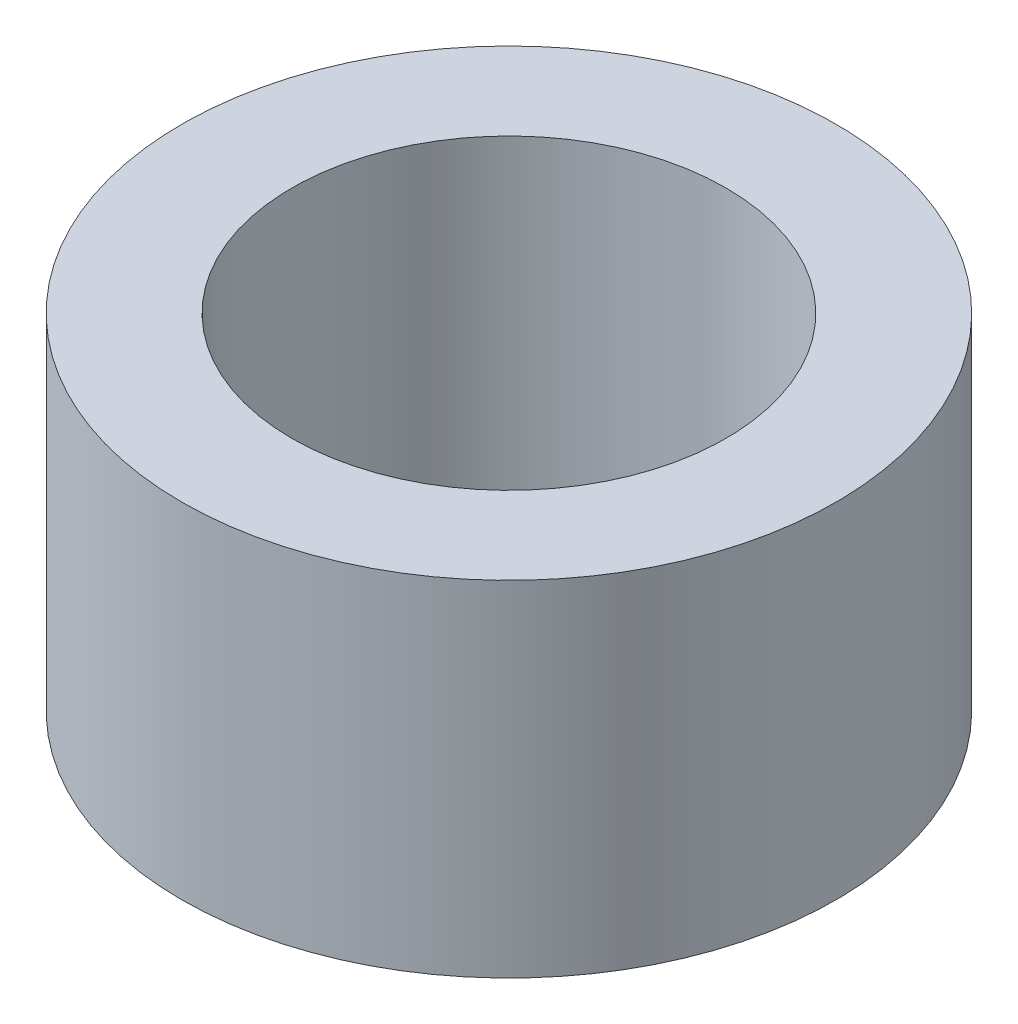
from build123d import *

# Parameters (mm, degrees)
SKETCH1_R           = 9.5
SKETCH1_R_2         = 6.3
BOSS_EXTRUDE1_DEPTH = 10


with BuildPart() as part:
    # Sketch1 → Boss-Extrude1 (new body)
    with BuildSketch(Plane(origin=(0, 0, 0), x_dir=(1, 0, 0), z_dir=(0, 1, 0))):
        with Locations(Location((0, 0, 0), (0, 0, 270))):  # turned: the seam where the file's is
            Circle(SKETCH1_R)
        with Locations(Location((0, 0, 0), (0, 0, 270))):  # turned: the seam where the file's is
            Circle(SKETCH1_R_2, mode=Mode.SUBTRACT)
    extrude(amount=BOSS_EXTRUDE1_DEPTH)


solid = part.part
